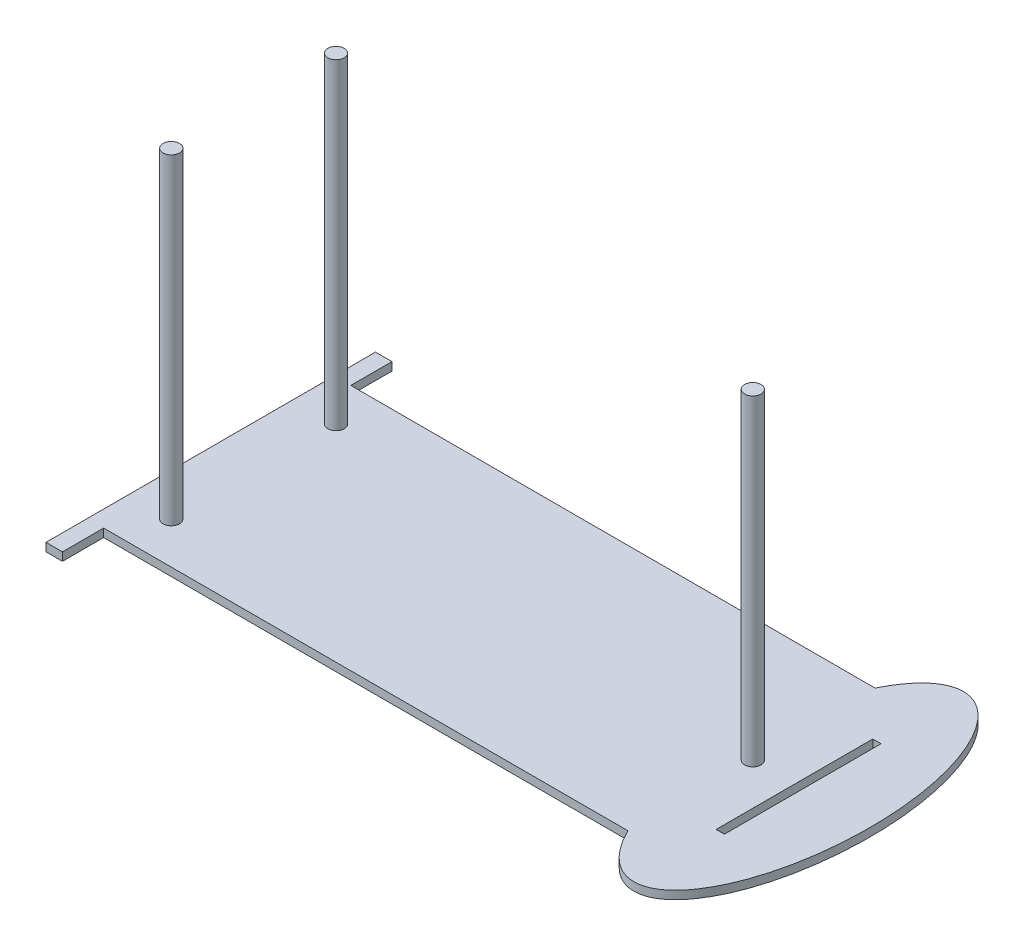
from build123d import *

# Parameters (mm, degrees)
SKETCH1_W           = 2.54
SKETCH1_H           = 48.297212565
BOSS_EXTRUDE1_DEPTH = 2.54
SKETCH2_R           = 2.54
BOSS_EXTRUDE2_DEPTH = 99.06
SKETCH6_W           = 80.01
SKETCH6_H           = 55.118
BOSS_EXTRUDE3_DEPTH = 7.62


with BuildPart() as part:
    # Sketch1 → Boss-Extrude1 (new body)
    with BuildSketch(Plane(origin=(0, 0, 0), x_dir=(1, 0, 0), z_dir=(0, 1, 0))):
        with BuildLine():
            Line((-83.440324594, 26.187530085), (78.212233052, 26.187530085))
            add(Edge.make_bspline(
                [(78.207608926, -50.012469915), (114.672846045, -124.454848136), (114.679675957, -11.906170246), (114.68650587, 100.642507644), (78.212233052, 26.187530085)],
                knots=[2.418926433, 2.418926433, 2.418926433, 4.712512983, 4.712512983, 7.006099534, 7.006099534, 7.006099534], degree=2, weights=[1, 0.411412318, 1, 0.411412318, 1]))
            Line((78.207608926, -50.012469915), (-83.440324594, -50.012469915))
            Line((-83.440324594, -50.012469915), (-83.440324594, -62.712469915))
            Line((-83.440324594, -62.712469915), (-88.520324594, -62.712469915))
            Line((-88.520324594, -62.712469915), (-88.520324594, -50.012469915))
            Line((-88.520324594, -50.012469915), (-88.520324594, 26.187530085))
            Line((-88.520324594, 26.187530085), (-88.520324594, 38.887530085))
            Line((-88.520324594, 38.887530085), (-83.440324594, 38.887530085))
            Line((-83.440324594, 38.887530085), (-83.440324594, 26.187530085))
        make_face()
        with Locations((92.729511542, -11.909961848)):
            Rectangle(SKETCH1_W, SKETCH1_H, mode=Mode.SUBTRACT)
    extrude(amount=BOSS_EXTRUDE1_DEPTH)

    # Sketch2 → Boss-Extrude2 (add)
    with BuildSketch(Plane(origin=(0, 2.54, 0), x_dir=(1, 0, 0), z_dir=(0, 1, 0))):
        with Locations((-75.403543329, 13.600337103)):
            Circle(SKETCH2_R)
        with Locations((-75.403543329, -37.201288275)):
            Circle(SKETCH2_R)
        with Locations((78.629546282, -11.912469915)):
            Circle(SKETCH2_R)
    extrude(amount=BOSS_EXTRUDE2_DEPTH)

    # Sketch6 → Boss-Extrude3 (add)
    with BuildSketch(Plane(origin=(0, 0, 0), x_dir=(-1, 0, 0), z_dir=(0, -1, 0))):
        with Locations((2.195576509, -11.912469915)):
            Rectangle(SKETCH6_W, SKETCH6_H)
    extrude(amount=BOSS_EXTRUDE3_DEPTH)


solid = part.part
